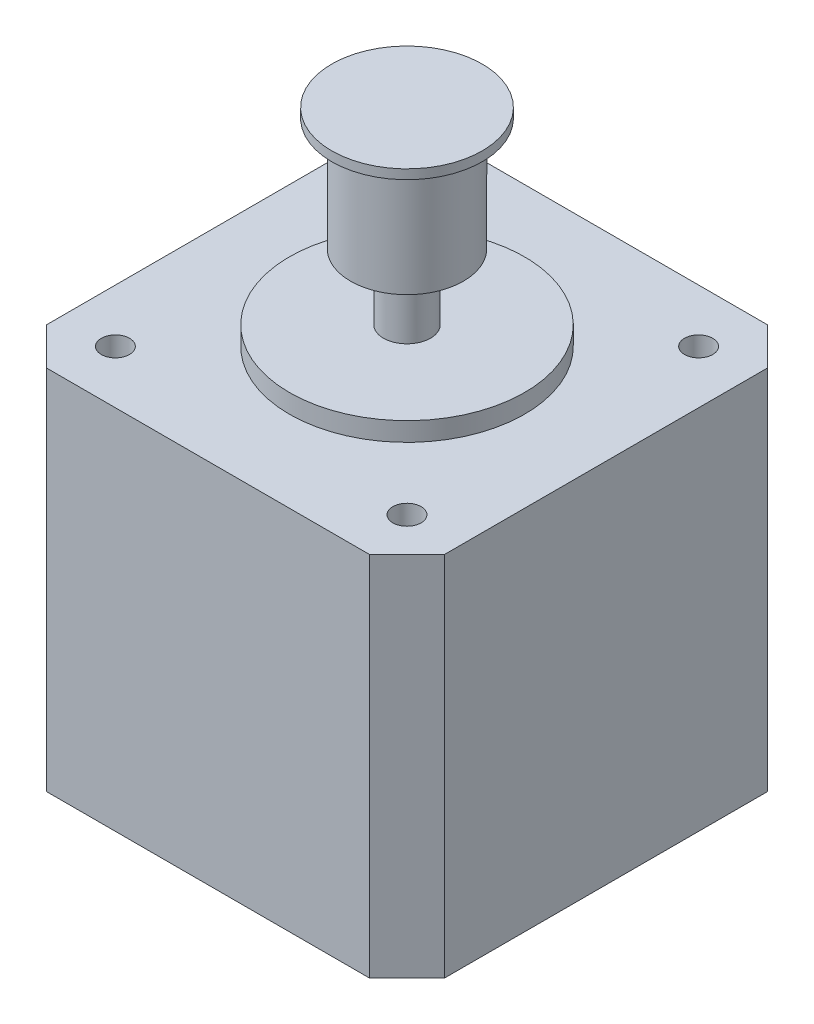
from build123d import *

# Parameters (mm, degrees)
CROQUIS1_W              = 42.3
CROQUIS1_H              = 42.3
CROQUIS1_R              = 1.5
SALIENTE_EXTRUIR1_DEPTH = 19.5
CROQUIS2_R              = 12.5
SALIENTE_EXTRUIR2_DEPTH = 2
CROQUIS3_R              = 2.5
SALIENTE_EXTRUIR3_DEPTH = 20
CROQUIS4_R              = 8
SALIENTE_EXTRUIR4_DEPTH = 1
CROQUIS5_R              = 6
SALIENTE_EXTRUIR5_DEPTH = 12
CHAFL_N1_SIZE           = 4


with BuildPart() as part:
    # Croquis1 → Saliente-Extruir1 (new body, symmetric)
    with BuildSketch(Plane(origin=(0, 0, 0), x_dir=(1, 0, 0), z_dir=(0, 1, 0))):
        Rectangle(CROQUIS1_W, CROQUIS1_H)
        with Locations((15.5, 15.5)):
            Circle(CROQUIS1_R, mode=Mode.SUBTRACT)
        with Locations((15.5, -15.5)):
            Circle(CROQUIS1_R, mode=Mode.SUBTRACT)
        with Locations((-15.5, -15.5)):
            Circle(CROQUIS1_R, mode=Mode.SUBTRACT)
        with Locations((-15.5, 15.5)):
            Circle(CROQUIS1_R, mode=Mode.SUBTRACT)
    extrude(amount=SALIENTE_EXTRUIR1_DEPTH, both=True)

    # Croquis2 → Saliente-Extruir2 (add)
    with BuildSketch(Plane(origin=(0, 19.5, 0), x_dir=(1, 0, 0), z_dir=(0, 1, 0))):
        Circle(CROQUIS2_R)
    extrude(amount=SALIENTE_EXTRUIR2_DEPTH)

    # Croquis3 → Saliente-Extruir3 (add)
    with BuildSketch(Plane(origin=(0, 21.5, 0), x_dir=(1, 0, 0), z_dir=(0, 1, 0))):
        Circle(CROQUIS3_R)
    extrude(amount=SALIENTE_EXTRUIR3_DEPTH)

    # Croquis4 → Saliente-Extruir4 (add)
    with BuildSketch(Plane(origin=(0, 41.5, 0), x_dir=(1, 0, 0), z_dir=(0, 1, 0))):
        Circle(CROQUIS4_R)
    extrude(amount=-SALIENTE_EXTRUIR4_DEPTH)

    # Croquis5 → Saliente-Extruir5 (add)
    with BuildSketch(Plane.XZ.offset(-40.5)):
        Circle(CROQUIS5_R)
    extrude(amount=SALIENTE_EXTRUIR5_DEPTH)

    # Chaflán1
    chafl_n1_edges = [part.edges().sort_by_distance(p)[0] for p in [
        (21.15, 0, 21.15),
        (-21.15, 0, 21.15),
        (-21.15, 0, -21.15),
        (21.15, 0, -21.15),
    ]]
    chamfer(chafl_n1_edges, length=CHAFL_N1_SIZE)


solid = part.part
